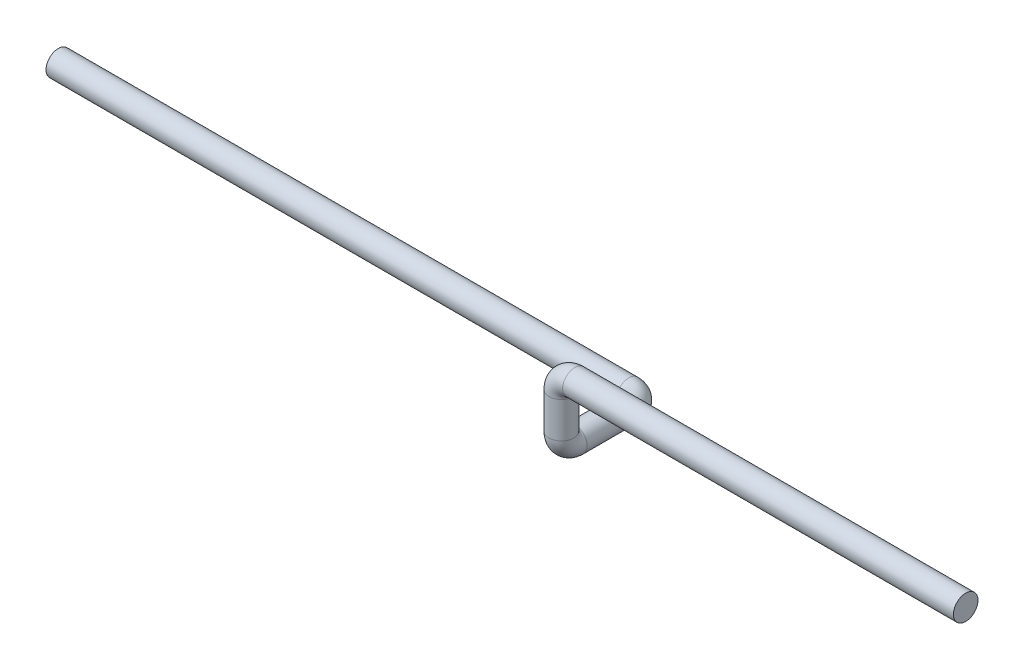
from build123d import *

# Parameters (mm, degrees)
CROQUIS1_R = 13.7


with BuildPart() as part:
    # Barrer1: sweep along a curve in space
    with BuildLine() as barrer1_path:
        Line((0, 0, 0), (-435, 0, 0))
        ThreePointArc((-435, 0, 0), (-445.606601718, -4.393398282, 0), (-450, -15, 0))
        Line((-450, -15, 0), (-450, -55, 0))
        ThreePointArc((-450, -55, 0), (-450, -65.606601718, -4.393398282), (-450, -70, -15))
        Line((-450, -70, -15), (-450, -70, -75))
        ThreePointArc((-450, -70, -75), (-454.393398282, -70, -85.606601718), (-465, -70, -90))
        Line((-465, -70, -90), (-1100, -70, -90))
    # Croquis1 → Barrer1 (sweep)
    with BuildSketch(Plane(origin=(0, 0, 0), x_dir=(0, 0, -1), z_dir=(1, 0, 0))):
        Circle(CROQUIS1_R)
    sweep(path=barrer1_path.line)


solid = part.part
